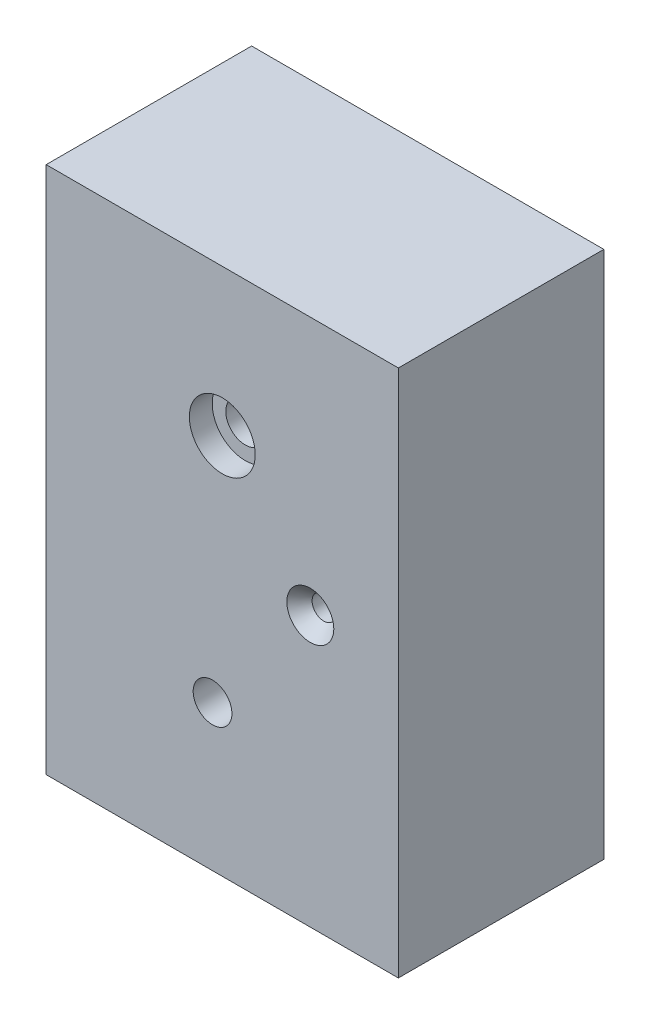
from build123d import *

# Parameters (mm, degrees)
SKETCH1_W                                     = 300
SKETCH1_H                                     = 450
BOSS_EXTRUDE1_DEPTH                           = 175
CBORE_FOR_M30_HEX_HEAD_CAP_SCREW1_D           = 33
CBORE_FOR_M30_HEX_HEAD_CAP_SCREW1_CBORE_D     = 56.12
CBORE_FOR_M30_HEX_HEAD_CAP_SCREW1_CBORE_DEPTH = 19.48
M36X3_0_TAPPED_HOLE1_D                        = 33
HOLE1_D                                       = 20
HOLE1_CSINK_D                                 = 40
HOLE1_CSINK_ANGLE                             = 82


with BuildPart() as part:
    # Sketch1 → Boss-Extrude1 (new body)
    with BuildSketch(Plane.XY):
        with Locations((150, 225)):
            Rectangle(SKETCH1_W, SKETCH1_H)
    extrude(amount=BOSS_EXTRUDE1_DEPTH)

    # CBORE for M30 Hex Head Cap Screw1 (through all)
    with Locations(Plane.XY.offset(175)):
        with Locations((150, 325)):
            CounterBoreHole(CBORE_FOR_M30_HEX_HEAD_CAP_SCREW1_D / 2, CBORE_FOR_M30_HEX_HEAD_CAP_SCREW1_CBORE_D / 2, CBORE_FOR_M30_HEX_HEAD_CAP_SCREW1_CBORE_DEPTH)

    # M36x3.0 Tapped Hole1 (through all)
    with Locations(Plane.XY.offset(175)):
        with Locations((141.698240344, 124.123333408)):
            Hole(M36X3_0_TAPPED_HOLE1_D / 2)

    # Hole1 (through all)
    with Locations(Plane.XY.offset(175)):
        with Locations((225, 230)):
            CounterSinkHole(HOLE1_D / 2, HOLE1_CSINK_D / 2, counter_sink_angle=HOLE1_CSINK_ANGLE)


solid = part.part
